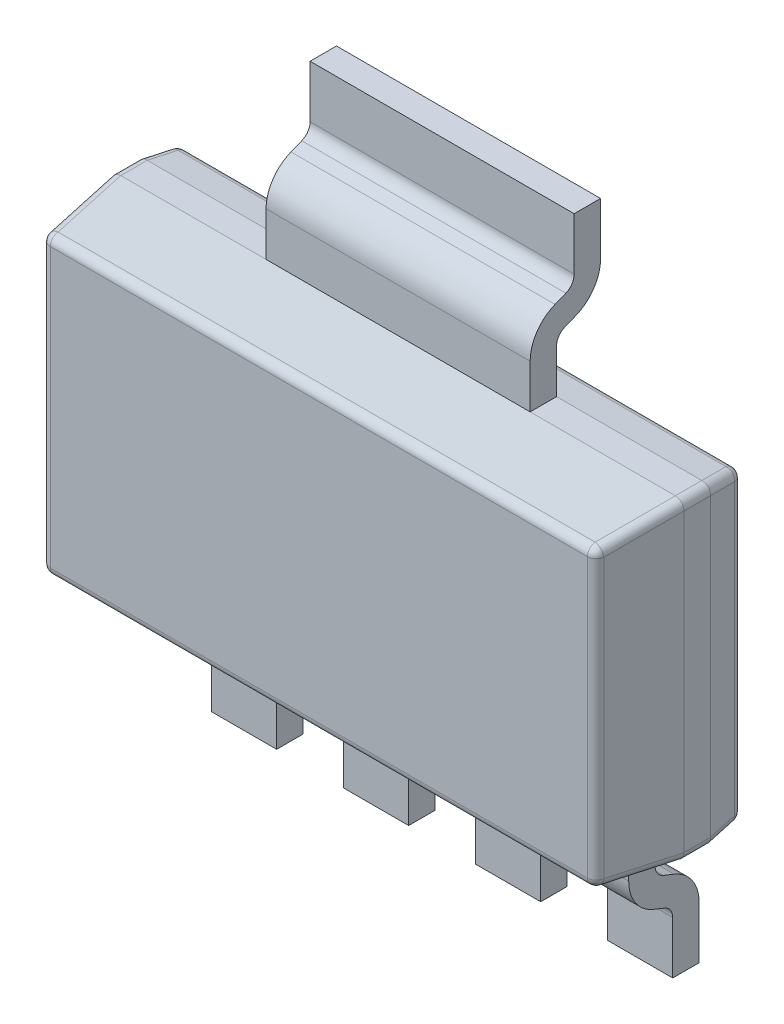
from build123d import *

# Parameters (mm, degrees)
SKETCH1_W             = 6.5
SKETCH1_H             = 3.56
EXTRUDE1_DEPTH        = 1.6
CHAMFER1_SIZE         = 0.9
CHAMFER1_SIZE2        = 0.110506105
CHAMFER1_PART_2_SIZE  = 0.9
CHAMFER1_PART_2_SIZE2 = 0.110506105
CHAMFER1_PART_3_SIZE  = 0.9
CHAMFER1_PART_3_SIZE2 = 0.110506105
CHAMFER1_PART_4_SIZE  = 0.9
CHAMFER1_PART_4_SIZE2 = 0.110506105
CHAMFER2_SIZE         = 0.4
CHAMFER2_SIZE2        = 0.049113824
CHAMFER2_PART_2_SIZE  = 0.4
CHAMFER2_PART_2_SIZE2 = 0.049113824
CHAMFER2_PART_3_SIZE  = 0.4
CHAMFER2_PART_3_SIZE2 = 0.049113824
CHAMFER2_PART_4_SIZE  = 0.4
CHAMFER2_PART_4_SIZE2 = 0.049113824
SKETCH2_W             = 0.74
SKETCH2_H             = 1.7
SKETCH2_W_2           = 3
EXTRUDE2_DEPTH        = 0.8
EXTRUDE3_DEPTH        = 6.87
FILLET1_R             = 0.1


with BuildPart() as part:
    # Sketch1 → Extrude1 (new body)
    with BuildSketch(Plane.XY.offset(0.1)):
        Rectangle(SKETCH1_W, SKETCH1_H)
    extrude(amount=EXTRUDE1_DEPTH)

    # Chamfer1
    chamfer1_edges = [part.edges().sort_by_distance(p)[0] for p in [
        (3.25, 0, 1.7),
    ]]
    chamfer1_side = [part.faces().sort_by_distance(p)[0] for p in [
        (3.25, 0, 0.9),
    ]]
    chamfer(chamfer1_edges, length=CHAMFER1_SIZE, length2=CHAMFER1_SIZE2, reference=chamfer1_side[0])

    # Chamfer1 part 2
    chamfer1_part_2_edges = [part.edges().sort_by_distance(p)[0] for p in [
        (0, 1.78, 1.7),
    ]]
    chamfer1_part_2_side = [part.faces().sort_by_distance(p)[0] for p in [
        (0, 1.78, 0.9),
    ]]
    chamfer(chamfer1_part_2_edges, length=CHAMFER1_PART_2_SIZE, length2=CHAMFER1_PART_2_SIZE2, reference=chamfer1_part_2_side[0])

    # Chamfer1 part 3
    chamfer1_part_3_edges = [part.edges().sort_by_distance(p)[0] for p in [
        (-3.25, 0, 1.7),
    ]]
    chamfer1_part_3_side = [part.faces().sort_by_distance(p)[0] for p in [
        (-3.25, 0, 0.9),
    ]]
    chamfer(chamfer1_part_3_edges, length=CHAMFER1_PART_3_SIZE, length2=CHAMFER1_PART_3_SIZE2, reference=chamfer1_part_3_side[0])

    # Chamfer1 part 4
    chamfer1_part_4_edges = [part.edges().sort_by_distance(p)[0] for p in [
        (0, -1.78, 1.7),
    ]]
    chamfer1_part_4_side = [part.faces().sort_by_distance(p)[0] for p in [
        (0, -1.78, 0.9),
    ]]
    chamfer(chamfer1_part_4_edges, length=CHAMFER1_PART_4_SIZE, length2=CHAMFER1_PART_4_SIZE2, reference=chamfer1_part_4_side[0])

    # Chamfer2
    chamfer2_edges = [part.edges().sort_by_distance(p)[0] for p in [
        (0, 1.78, 0.1),
    ]]
    chamfer2_side = [part.faces().sort_by_distance(p)[0] for p in [
        (0, 1.78, 0.45),
    ]]
    chamfer(chamfer2_edges, length=CHAMFER2_SIZE, length2=CHAMFER2_SIZE2, reference=chamfer2_side[0])

    # Chamfer2 part 2
    chamfer2_part_2_edges = [part.edges().sort_by_distance(p)[0] for p in [
        (3.25, 0, 0.1),
    ]]
    chamfer2_part_2_side = [part.faces().sort_by_distance(p)[0] for p in [
        (3.25, 0, 0.45),
    ]]
    chamfer(chamfer2_part_2_edges, length=CHAMFER2_PART_2_SIZE, length2=CHAMFER2_PART_2_SIZE2, reference=chamfer2_part_2_side[0])

    # Chamfer2 part 3
    chamfer2_part_3_edges = [part.edges().sort_by_distance(p)[0] for p in [
        (0, -1.78, 0.1),
    ]]
    chamfer2_part_3_side = [part.faces().sort_by_distance(p)[0] for p in [
        (0, -1.78, 0.45),
    ]]
    chamfer(chamfer2_part_3_edges, length=CHAMFER2_PART_3_SIZE, length2=CHAMFER2_PART_3_SIZE2, reference=chamfer2_part_3_side[0])

    # Chamfer2 part 4
    chamfer2_part_4_edges = [part.edges().sort_by_distance(p)[0] for p in [
        (-3.25, 0, 0.1),
    ]]
    chamfer2_part_4_side = [part.faces().sort_by_distance(p)[0] for p in [
        (-3.25, 0, 0.45),
    ]]
    chamfer(chamfer2_part_4_edges, length=CHAMFER2_PART_4_SIZE, length2=CHAMFER2_PART_4_SIZE2, reference=chamfer2_part_4_side[0])

    # Sketch2 → Extrude2 (add)
    with BuildSketch(Plane.XY):
        with Locations((-0.75, -2.63)):
            Rectangle(SKETCH2_W, SKETCH2_H)
        with Locations((-2.25, -2.63)):
            Rectangle(SKETCH2_W, SKETCH2_H)
        with Locations((0.75, -2.63)):
            Rectangle(SKETCH2_W, SKETCH2_H)
        with Locations((2.25, -2.63)):
            Rectangle(SKETCH2_W, SKETCH2_H)
        with Locations((0, 2.63)):
            Rectangle(SKETCH2_W_2, SKETCH2_H)
    extrude(amount=EXTRUDE2_DEPTH)

    # Sketch3 → Extrude3 (cut, through all)
    with BuildSketch(Plane(origin=(2.62, 0, 0), x_dir=(0, 0, -1), z_dir=(1, 0, 0))):
        with BuildLine():
            Line((-0.5, -1.78), (-0.5, -2.278445056))
            ThreePointArc((-0.5, -2.278445056), (-0.474210085, -2.362539377), (-0.405708601, -2.417716559))
            Line((-0.405708601, -2.417716559), (-0.282874196, -2.466850322))
            ThreePointArc((-0.282874196, -2.466850322), (-0.077369746, -2.632381868), (0, -2.884664833))
            Line((0, -2.884664833), (0, -1.78))
            Line((0, -1.78), (-0.5, -1.78))
        make_face()
        with BuildLine():
            Line((-0.517125804, -2.696259567), (-0.394291399, -2.745393329))
            ThreePointArc((-0.394291399, -2.745393329), (-0.325789915, -2.800570511), (-0.3, -2.884664833))
            Line((-0.3, -2.884664833), (-0.3, -3.48))
            Line((-0.3, -3.48), (-0.8, -3.48))
            Line((-0.8, -3.48), (-0.8, -2.278445056))
            ThreePointArc((-0.8, -2.278445056), (-0.722630254, -2.53072802), (-0.517125804, -2.696259567))
        make_face()
        with BuildLine():
            Line((-0.5, 1.78), (-0.5, 2.278445056))
            ThreePointArc((-0.5, 2.278445056), (-0.474210085, 2.362539377), (-0.405708601, 2.417716559))
            Line((-0.405708601, 2.417716559), (-0.282874196, 2.466850322))
            ThreePointArc((-0.282874196, 2.466850322), (-0.077369746, 2.632381868), (0, 2.884664833))
            Line((0, 2.884664833), (0, 1.78))
            Line((0, 1.78), (-0.5, 1.78))
        make_face()
        with BuildLine():
            Line((-0.3, 3.48), (-0.8, 3.48))
            Line((-0.8, 3.48), (-0.8, 2.278445056))
            ThreePointArc((-0.8, 2.278445056), (-0.722630254, 2.53072802), (-0.517125804, 2.696259567))
            Line((-0.517125804, 2.696259567), (-0.394291399, 2.745393329))
            ThreePointArc((-0.394291399, 2.745393329), (-0.325789915, 2.800570511), (-0.3, 2.884664833))
            Line((-0.3, 2.884664833), (-0.3, 3.48))
        make_face()
    extrude(amount=-EXTRUDE3_DEPTH, mode=Mode.SUBTRACT)

    # Fillet1
    fillet1_edges = [part.edges().sort_by_distance(p)[0] for p in [
        (-3.139493895, 0, 1.7),
        (0, -1.669493895, 1.7),
        (3.139493895, 0, 1.7),
        (0, 1.669493895, 1.7),
        (-3.25, 1.78, 0.65),
        (3.25, 1.78, 0.65),
        (3.25, -1.78, 0.65),
        (-3.25, -1.78, 0.65),
        (3.194746948, -1.724746948, 1.25),
        (-3.194746948, -1.724746948, 1.25),
        (3.194746948, 1.724746948, 1.25),
        (-3.194746948, 1.724746948, 1.25),
        (-3.200886176, 0, 0.1),
        (0, 1.730886176, 0.1),
        (3.200886176, 0, 0.1),
        (0, -1.730886176, 0.1),
        (-3.225443088, 1.755443088, 0.3),
        (3.225443088, 1.755443088, 0.3),
        (-3.225443088, -1.755443088, 0.3),
        (3.225443088, -1.755443088, 0.3),
    ]]
    fillet(fillet1_edges, radius=FILLET1_R)


solid = part.part
